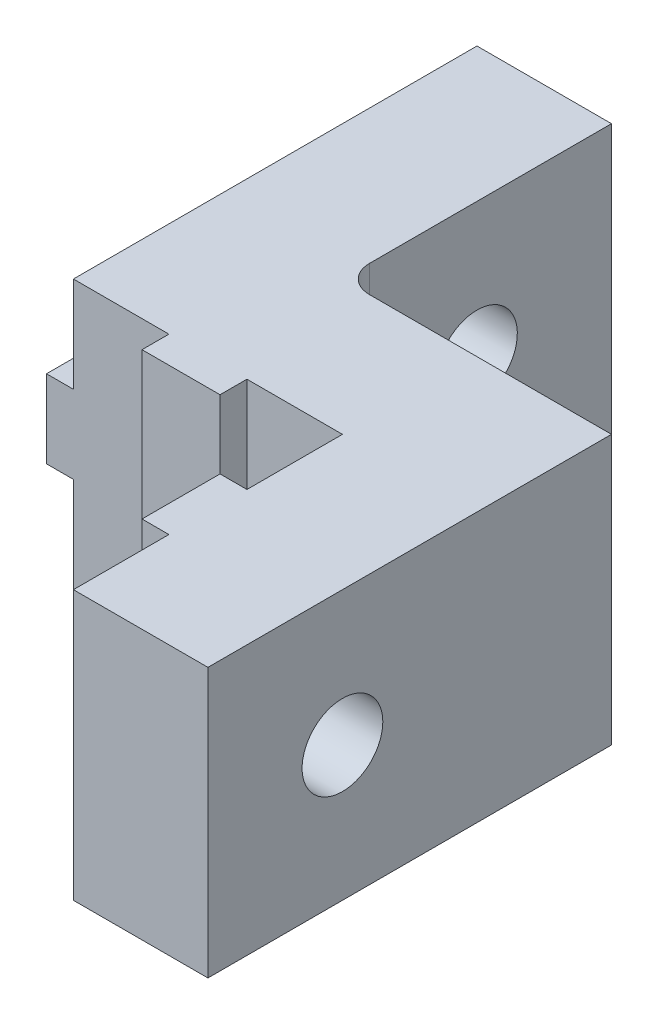
from build123d import *

# Parameters (mm, degrees)
MAIN_DEPTH             = 25
SKETCH2_W              = 10
SKETCH2_H              = 10
VERTICALFORM_DEPTH     = 11
SKETCH3_R              = 1.5
MAKERBEAMFIXHOLE_DEPTH = 17
FILLET1_R              = 1


with BuildPart() as part:
    # Sketch1 → Main (new body)
    with BuildSketch(Plane.XY):
        Polygon((0, 10), (0, 6.45), (-1, 6.45), (-1, 3.55), (0, 3.55), (0, 0), (15, 0), (15, 10), align=None)
    extrude(amount=MAIN_DEPTH)

    # Sketch2 → VerticalForm (cut, through all)
    with BuildSketch(Plane(origin=(0, 0, 0), x_dir=(-1, 0, 0), z_dir=(0, -1, 0))):
        Polygon((1, -15), (1, -25), (-10, -25), (-10, -21.45), (-9, -21.45), (-9, -18.55), (-10, -18.55), (-10, -15), (-6.45, -15), (-6.45, -16), (-3.55, -16), (-3.55, -15), align=None)
        with Locations((-10, -5)):
            Rectangle(SKETCH2_W, SKETCH2_H)
    extrude(amount=-VERTICALFORM_DEPTH, mode=Mode.SUBTRACT)

    # Sketch3 → MakerBeamFixHole (cut, through all)
    with BuildSketch(Plane(origin=(15, 0, 0), x_dir=(0, 0, -1), z_dir=(1, 0, 0))):
        with Locations((-5, 5)):
            Circle(SKETCH3_R)
        with Locations((-20, 5)):
            Circle(SKETCH3_R)
    extrude(amount=-MAKERBEAMFIXHOLE_DEPTH, mode=Mode.SUBTRACT)

    # Fillet1
    fillet1_edges = [part.edges().sort_by_distance(p)[0] for p in [
        (5, 5, 10),
    ]]
    fillet(fillet1_edges, radius=FILLET1_R)


solid = part.part
